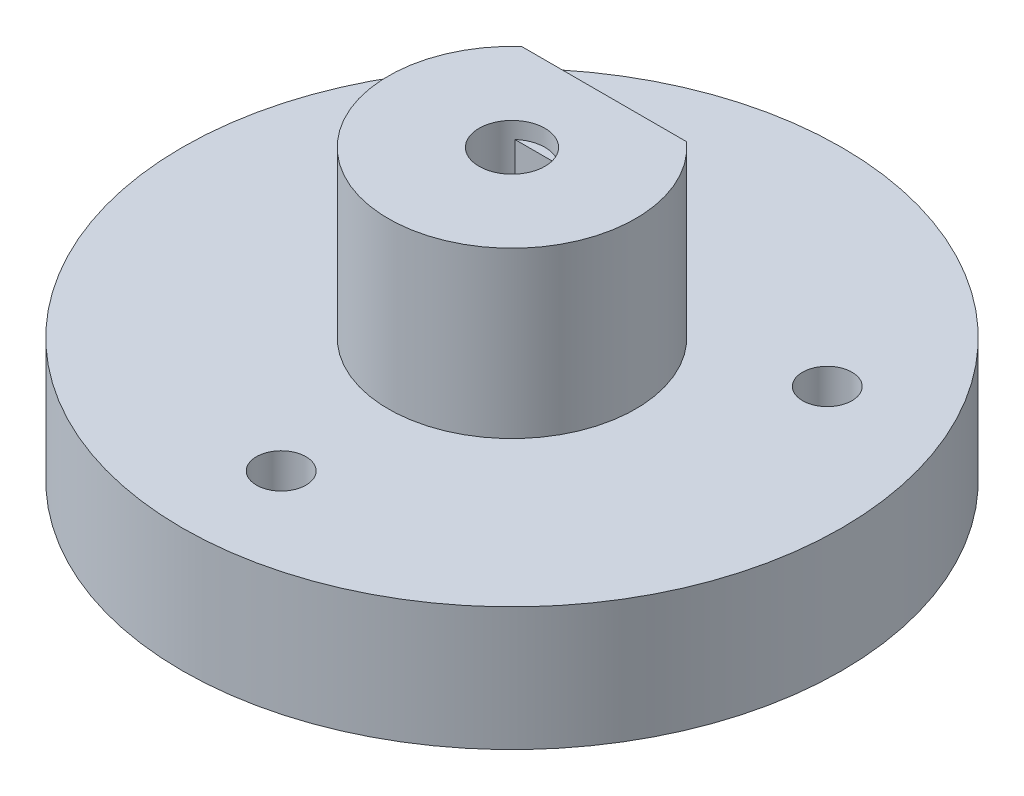
from build123d import *

# Parameters (mm, degrees)
CROQUIS1_R              = 20
SALIENTE_EXTRUIR1_DEPTH = 7.5
CROQUIS2_R              = 7.5
SALIENTE_EXTRUIR2_DEPTH = 10
CORTAR_EXTRUIR1_DEPTH   = 10
CORTAR_EXTRUIR2_DEPTH   = 3
CORTAR_EXTRUIR3_DEPTH   = 10
CROQUIS8_R              = 1.875
CORTAR_EXTRUIR4_DEPTH   = 3
CROQUIS9_R              = 1.5
CORTAR_EXTRUIR5_DEPTH   = 10
CROQUIS10_R             = 2
CORTAR_EXTRUIR7_DEPTH   = 1


with BuildPart() as part:
    # Croquis1 → Saliente-Extruir1 (new body)
    with BuildSketch(Plane(origin=(0, 0, 0), x_dir=(1, 0, 0), z_dir=(0, 1, 0))):
        Circle(CROQUIS1_R)
    extrude(amount=SALIENTE_EXTRUIR1_DEPTH)

    # Croquis2 → Saliente-Extruir2 (add)
    with BuildSketch(Plane(origin=(0, 7.5, 0), x_dir=(1, 0, 0), z_dir=(0, 1, 0))):
        Circle(CROQUIS2_R)
    extrude(amount=SALIENTE_EXTRUIR2_DEPTH)

    # Croquis5 → Cortar-Extruir1 (cut)
    with BuildSketch(Plane(origin=(0, 17.5, 0), x_dir=(1, 0, 0), z_dir=(0, 1, 0))):
        with BuildLine():
            Line((-5, 5.590169944), (5, 5.590169944))
            ThreePointArc((5, 5.590169944), (0, 7.5), (-5, 5.590169944))
        make_face()
    extrude(amount=-CORTAR_EXTRUIR1_DEPTH, mode=Mode.SUBTRACT)

    # Croquis6 → Cortar-Extruir2 (cut)
    with BuildSketch(Plane(origin=(0, 0, -5.590169944), x_dir=(-1, 0, 0), z_dir=(0, 0, -1))):
        Polygon((0, 8.458548116), (3.5, 10.479274058), (3.5, 14.520725942), (0, 16.541451884), (-3.5, 14.520725942), (-3.5, 10.479274058), align=None)
    extrude(amount=-CORTAR_EXTRUIR2_DEPTH, mode=Mode.SUBTRACT)

    # Croquis7 → Cortar-Extruir3 (cut)
    with BuildSketch(Plane(origin=(0, 17.5, 0), x_dir=(1, 0, 0), z_dir=(0, 1, 0))):
        with BuildLine():
            Line((-1.322875656, 1.5), (1.322875656, 1.5))
            ThreePointArc((1.322875656, 1.5), (0, -2), (-1.322875656, 1.5))
        make_face()
    extrude(amount=-CORTAR_EXTRUIR3_DEPTH, mode=Mode.SUBTRACT)

    # Croquis8 → Cortar-Extruir4 (cut)
    with BuildSketch(Plane(origin=(0, 0, -2.590169944), x_dir=(-1, 0, 0), z_dir=(0, 0, -1))):
        with Locations((0, 12.5)):
            Circle(CROQUIS8_R)
    extrude(amount=-CORTAR_EXTRUIR4_DEPTH, mode=Mode.SUBTRACT)

    # Croquis9 → Cortar-Extruir5 (cut)
    with BuildSketch(Plane(origin=(0, 7.5, 0), x_dir=(1, 0, 0), z_dir=(0, 1, 0))):
        with Locations((-12.124355653, 7)):
            Circle(CROQUIS9_R)
        with Locations((12.124355653, 7)):
            Circle(CROQUIS9_R)
        with Locations((0, -14)):
            Circle(CROQUIS9_R)
    extrude(amount=-CORTAR_EXTRUIR5_DEPTH, mode=Mode.SUBTRACT)

    # Croquis10 → Cortar-Extruir7 (cut)
    with BuildSketch(Plane(origin=(0, 17.5, 0), x_dir=(1, 0, 0), z_dir=(0, 1, 0))):
        Circle(CROQUIS10_R)
    extrude(amount=-CORTAR_EXTRUIR7_DEPTH, mode=Mode.SUBTRACT)


solid = part.part
